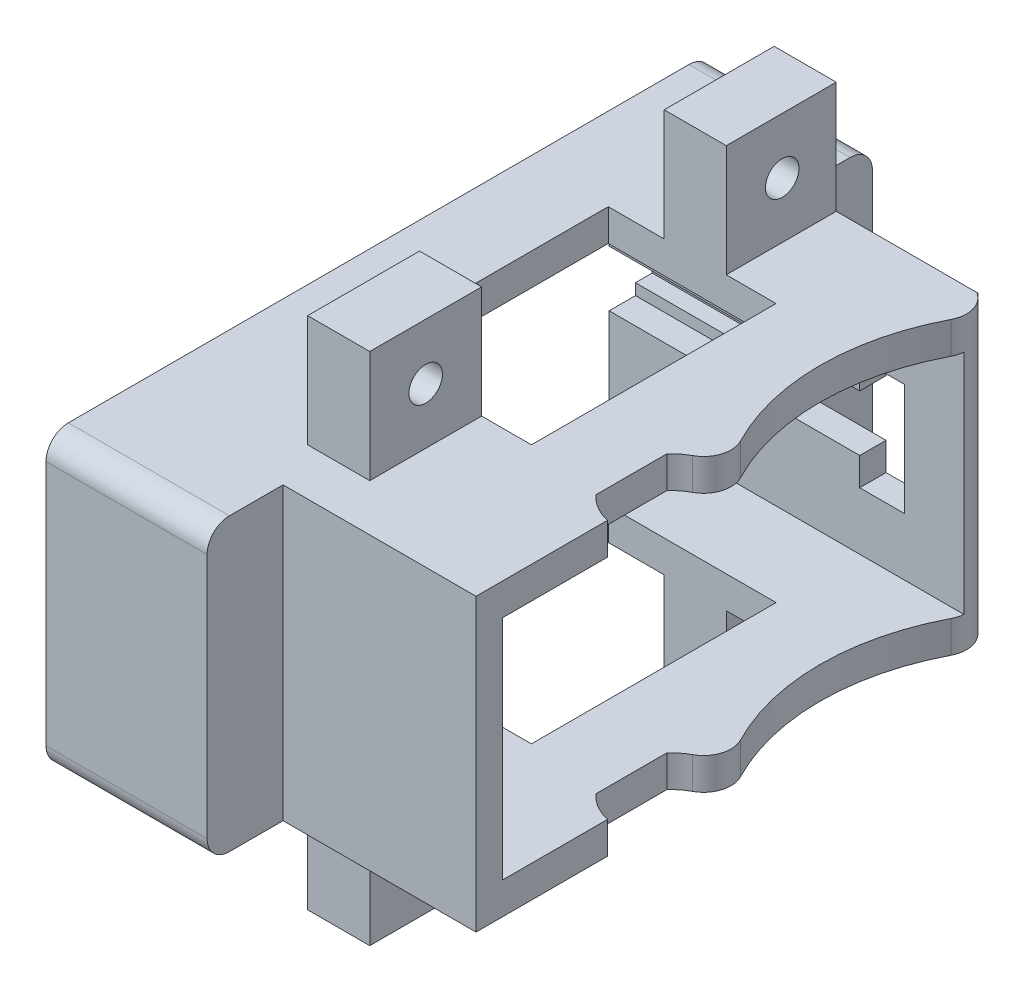
from build123d import *

# Parameters (mm, degrees)
EXTRUDE_1_DEPTH          = 3
PATTERN_LINEAR_2_COUNT   = 2
PATTERN_LINEAR_2_PITCH   = 23
EXTRUDE_2_DEPTH          = 26
SKETCH_3_R               = 1.85
CUT_EXTRUDE_1_DEPTH      = 10
CUT_EXTRUDE_2_DEPTH      = 24
CUT_EXTRUDE_START        = -2.5
SKETCH_5_W               = 4
SKETCH_5_H               = 10
CUT_EXTRUDE_3_DEPTH      = 2.5
FILLET_3_R               = 2
EXTRUDE_START            = -10
SKETCH_7_W               = 9.83
SKETCH_7_H               = 10
SKETCH_7_W_2             = 10
EXTRUDE_4_DEPTH          = 5.55
CUT_EXTRUDE_4_REACH      = 21.469
SKETCH_8_R               = 1.5
SKETCH_10_W              = 15
SKETCH_10_H              = 21.87
CUT_EXTRUDE_5_DEPTH      = 37
CUT_EXTRUDE_6_DEPTH      = 11
CUT_EXTRUDE_6_DEPTH_BACK = 37
SKETCH_12_R              = 1.85
EXTRUDE_5_DEPTH          = 2.4
SKETCH_13_W              = 10.554856858
SKETCH_13_H              = 20
CUT_EXTRUDE_7_DEPTH      = 3.419156865
SKETCH_14_W              = 41.2
SKETCH_14_H              = 20.3
CUT_EXTRUDE_8_DEPTH      = 32.719156865


with BuildPart() as part:
    # Эскиз1 → Бобышка-Вытянуть1 (new body)
    with BuildSketch(Plane(origin=(0, 0, 0), x_dir=(1, 0, 0), z_dir=(0, 1, 0))):
        with BuildLine():
            Line((-47.15, 10.148849956), (-17.708435007, 10.148849956))
            ThreePointArc((-17.708435007, 10.148849956), (-17.806599121, 9.727806242), (-17.973176083, 9.328849956))
            ThreePointArc((-17.973176083, 9.328849956), (-20.25, 0), (-17.973176083, -9.328849956))
            ThreePointArc((-17.973176083, -9.328849956), (-17.79606457, -11.292053253), (-19.04716249, -12.815302961))
            ThreePointArc((-19.04716249, -12.815302961), (-19.687557209, -13.232647403), (-20.25, -13.750276505))
            Line((-20.25, -13.750276505), (-20.25, -30.751150044))
            Line((-20.25, -30.751150044), (-47.15, -30.751150044))
            Line((-47.15, -30.751150044), (-47.15, 10.148849956))
        make_face()
    extrude(amount=EXTRUDE_1_DEPTH)


with BuildPart() as pattern_linear_2_1:
    # Линейный массив2: pattern copy
    add(part.part.moved(Location(Vector(0, 1, 0) * (1 * PATTERN_LINEAR_2_PITCH))))


with BuildPart() as part_1:
    add(part.part)

    add(pattern_linear_2_1.part)  # Бобышка-Вытянуть2 merges Линейный массив2_1
    # Эскиз2 → Бобышка-Вытянуть2 (add, through all)
    with BuildSketch(Plane(origin=(0, 26, 0), x_dir=(1, 0, 0), z_dir=(0, 1, 0))):
        with BuildLine():
            ThreePointArc((-18.778786242, 12.648849956), (-17.890693286, 11.549948159), (-17.708435007, 10.148849956))
            Line((-17.708435007, 10.148849956), (-47.15, 10.148849956))
            Line((-47.15, 10.148849956), (-47.15, 19.438849956))
            Line((-47.15, 19.438849956), (-35.15, 19.438849956))
            Line((-35.15, 19.438849956), (-35.15, 12.648849956))
            Line((-35.15, 12.648849956), (-18.778786242, 12.648849956))
        make_face()
        with BuildLine():
            Line((-20.25, -19.978716958), (-20.25, -30.751150044))
            Line((-20.25, -30.751150044), (-47.15, -30.751150044))
            Line((-47.15, -30.751150044), (-47.15, -40.041150044))
            Line((-47.15, -40.041150044), (-35.15, -40.041150044))
            Line((-35.15, -40.041150044), (-35.15, -33.251150044))
            Line((-35.15, -33.251150044), (-17.75, -33.251150044))
            Line((-17.75, -33.251150044), (-17.75, -21.378462168))
            ThreePointArc((-17.75, -21.378462168), (-19.111760818, -20.878198779), (-20.25, -19.978716958))
        make_face()
    extrude(amount=-EXTRUDE_2_DEPTH)

    # Эскиз3 → Вырез-Вытянуть1 (cut)
    with BuildSketch(Plane.ZY.offset(47.15)):
        with Locations((-13.948849956, 8)):
            Circle(SKETCH_3_R)
        with Locations((-13.948849956, 18)):
            Circle(SKETCH_3_R)
        with Locations((34.551150044, 18)):
            Circle(SKETCH_3_R)
        with Locations((34.551150044, 8)):
            Circle(SKETCH_3_R)
    extrude(amount=-CUT_EXTRUDE_1_DEPTH, mode=Mode.SUBTRACT)

    # Эскиз4 → Вырез-Вытянуть2 (cut)
    with BuildSketch(Plane.ZY.offset(47.15)):
        Polygon((-10.148849956, 15.5), (-12.648849956, 15.5), (-12.648849956, 14.5), (-14.148849956, 14.5), (-14.148849956, 11.5), (-12.648849956, 11.5), (-12.648849956, 10.5), (-10.148849956, 10.5), align=None)
    extrude(amount=-CUT_EXTRUDE_2_DEPTH, mode=Mode.SUBTRACT)

    # Эскиз5 → Вырез-Вытянуть3 (cut)
    with BuildSketch(Plane(origin=(0, 0, -12.648849956), x_dir=(-1, 0, 0), z_dir=(0, 0, -1)).offset(CUT_EXTRUDE_START)):
        with Locations((25.15, 13)):
            Rectangle(SKETCH_5_W, SKETCH_5_H)
    extrude(amount=CUT_EXTRUDE_3_DEPTH, mode=Mode.SUBTRACT)

    # Скругление3
    fillet_3_edges = [part_1.edges().sort_by_distance(p)[0] for p in [
        (-41.15, 26, -19.438849956),
        (-41.15, 0, -19.438849956),
        (-41.15, 0, 40.041150044),
        (-41.15, 26, 40.041150044),
    ]]
    fillet(fillet_3_edges, radius=FILLET_3_R)

    # Эскиз7 → Бобышка-Вытянуть4 (add)
    with BuildSketch(Plane.ZY.offset(47.15).offset(EXTRUDE_START)):
        with Locations((-7.733849956, 31)):
            Rectangle(SKETCH_7_W, SKETCH_7_H)
        with Locations((24.051150044, 31)):
            Rectangle(SKETCH_7_W_2, SKETCH_7_H)
        with Locations((-7.733849956, -5)):
            Rectangle(SKETCH_7_W, SKETCH_7_H)
        with Locations((24.051150044, -5)):
            Rectangle(SKETCH_7_W_2, SKETCH_7_H)
    extrude(amount=-EXTRUDE_4_DEPTH)

    # Эскиз8 → Вырез-Вытянуть4 (cut, up to next)
    with BuildSketch(Plane.ZY.offset(37.15), mode=Mode.PRIVATE) as cut_extrude_4_sk1:
        with Locations((-7.818849956, -5)):
            Circle(SKETCH_8_R)
    cut_extrude_4_tool1 = extrude(cut_extrude_4_sk1.sketch, amount=-CUT_EXTRUDE_4_REACH, mode=Mode.PRIVATE) & part_1.part
    add(cut_extrude_4_tool1.solids().sort_by_distance((-37.15, -5, -7.81885))[0], mode=Mode.SUBTRACT)
    # Эскиз8 → Вырез-Вытянуть4 (cut, up to next)
    with BuildSketch(Plane.ZY.offset(37.15), mode=Mode.PRIVATE) as cut_extrude_4_sk2:
        with Locations((-7.818849956, 31)):
            Circle(SKETCH_8_R)
    cut_extrude_4_tool2 = extrude(cut_extrude_4_sk2.sketch, amount=-CUT_EXTRUDE_4_REACH, mode=Mode.PRIVATE) & part_1.part
    add(cut_extrude_4_tool2.solids().sort_by_distance((-37.15, 31, -7.81885))[0], mode=Mode.SUBTRACT)
    # Эскиз8 → Вырез-Вытянуть4 (cut, up to next)
    with BuildSketch(Plane.ZY.offset(37.15), mode=Mode.PRIVATE) as cut_extrude_4_sk3:
        with Locations((24.051150044, 31)):
            Circle(SKETCH_8_R)
    cut_extrude_4_tool3 = extrude(cut_extrude_4_sk3.sketch, amount=-CUT_EXTRUDE_4_REACH, mode=Mode.PRIVATE) & part_1.part
    add(cut_extrude_4_tool3.solids().sort_by_distance((-37.15, 31, 24.05115))[0], mode=Mode.SUBTRACT)
    # Эскиз8 → Вырез-Вытянуть4 (cut, up to next)
    with BuildSketch(Plane.ZY.offset(37.15), mode=Mode.PRIVATE) as cut_extrude_4_sk4:
        with Locations((24.051150044, -5)):
            Circle(SKETCH_8_R)
    cut_extrude_4_tool4 = extrude(cut_extrude_4_sk4.sketch, amount=-CUT_EXTRUDE_4_REACH, mode=Mode.PRIVATE) & part_1.part
    add(cut_extrude_4_tool4.solids().sort_by_distance((-37.15, -5, 24.05115))[0], mode=Mode.SUBTRACT)

    # Эскиз10 → Вырез-Вытянуть5 (cut, through all)
    with BuildSketch(Plane.XZ):
        with Locations((-34.65, 8.116150044)):
            Rectangle(SKETCH_10_W, SKETCH_10_H)
    extrude(amount=-CUT_EXTRUDE_5_DEPTH, mode=Mode.SUBTRACT)

    # Эскиз11 → Вырез-Вытянуть6 (cut, two sides)
    with BuildSketch(Plane(origin=(0, 26, 0), x_dir=(1, 0, 0), z_dir=(0, 1, 0))) as cut_extrude_6_sk:
        with BuildLine():
            Line((-17.75, -33.251150044), (-17.75, -21.378462168))
            ThreePointArc((-17.75, -21.378462168), (-19.111760818, -20.878198779), (-20.25, -19.978716958))
            Line((-20.25, -19.978716958), (-20.25, -13.750276505))
            ThreePointArc((-20.25, -13.750276505), (-19.687557209, -13.232647403), (-19.04716249, -12.815302961))
            ThreePointArc((-19.04716249, -12.815302961), (-17.79606457, -11.292053253), (-17.973176083, -9.328849956))
            ThreePointArc((-17.973176083, -9.328849956), (-20.25, 0), (-17.973176083, 9.328849956))
            ThreePointArc((-17.973176083, 9.328849956), (-17.754165646, 11.139735768), (-18.778786242, 12.648849956))
            Line((-18.778786242, 12.648849956), (-18.928786242, 12.648849956))
            Line((-18.928786242, 12.648849956), (-18.928786242, 12.569773384))
            ThreePointArc((-18.928786242, 12.569773384), (-17.909278274, 11.141591723), (-18.10631072, 9.397952548))
            ThreePointArc((-18.10631072, 9.397952548), (-20.4, 0), (-18.10631072, -9.397952548))
            ThreePointArc((-18.10631072, -9.397952548), (-17.939417179, -11.247894117), (-19.118336373, -12.683264034))
            ThreePointArc((-19.118336373, -12.683264034), (-19.80280754, -13.132362008), (-20.4, -13.6923182))
            Line((-20.4, -13.6923182), (-20.4, -20.036675263))
            ThreePointArc((-20.4, -20.036675263), (-19.264296699, -20.963699107), (-17.9, -21.500252655))
            Line((-17.9, -21.500252655), (-17.9, -33.251150044))
            Line((-17.9, -33.251150044), (-17.75, -33.251150044))
        make_face()
    extrude(amount=CUT_EXTRUDE_6_DEPTH, mode=Mode.SUBTRACT)
    extrude(cut_extrude_6_sk.sketch, amount=-CUT_EXTRUDE_6_DEPTH_BACK, mode=Mode.SUBTRACT)

    # Эскиз12 → Бобышка-Вытянуть5 (add)
    with BuildSketch(Plane.ZY.offset(47.15)):
        with BuildLine():
            Line((-17.438849956, 26), (38.041150044, 26))
            ThreePointArc((38.041150044, 26), (39.455363607, 25.414213562), (40.041150044, 24))
            Line((40.041150044, 24), (40.041150044, 2))
            ThreePointArc((40.041150044, 2), (39.455363607, 0.585786438), (38.041150044, 0))
            Line((38.041150044, 0), (-17.438849956, 0))
            ThreePointArc((-17.438849956, 0), (-18.853063518, 0.585786438), (-19.438849956, 2))
            Line((-19.438849956, 2), (-19.438849956, 24))
            ThreePointArc((-19.438849956, 24), (-18.853063518, 25.414213562), (-17.438849956, 26))
        make_face()
        with Locations((34.551150044, 18)):
            Circle(SKETCH_12_R, mode=Mode.SUBTRACT)
        with Locations((-13.948849956, 18)):
            Circle(SKETCH_12_R, mode=Mode.SUBTRACT)
        with Locations((-13.948849956, 8)):
            Circle(SKETCH_12_R, mode=Mode.SUBTRACT)
        with Locations((34.551150044, 8)):
            Circle(SKETCH_12_R, mode=Mode.SUBTRACT)
        Polygon((-10.148849956, 23), (-10.148849956, 15.5), (-12.648849956, 15.5), (-12.648849956, 14.5), (-14.148849956, 14.5), (-14.148849956, 11.5), (-12.648849956, 11.5), (-12.648849956, 10.5), (-10.148849956, 10.5), (-10.148849956, 3), (30.751150044, 3), (30.751150044, 23), align=None, mode=Mode.SUBTRACT)
    extrude(amount=EXTRUDE_5_DEPTH)

    # Эскиз13 → Вырез-Вытянуть7 (cut, through all)
    with BuildSketch(Plane.ZY.offset(20.25)):
        with Locations((25.473721615, 13)):
            Rectangle(SKETCH_13_W, SKETCH_13_H)
    extrude(amount=-CUT_EXTRUDE_7_DEPTH, mode=Mode.SUBTRACT)

    # Эскиз14 → Вырез-Вытянуть8 (cut, through all)
    with BuildSketch(Plane.ZY.offset(49.55)):
        with Locations((10.301150044, 13)):
            Rectangle(SKETCH_14_W, SKETCH_14_H)
    extrude(amount=-CUT_EXTRUDE_8_DEPTH, mode=Mode.SUBTRACT)


solid = part_1.part
